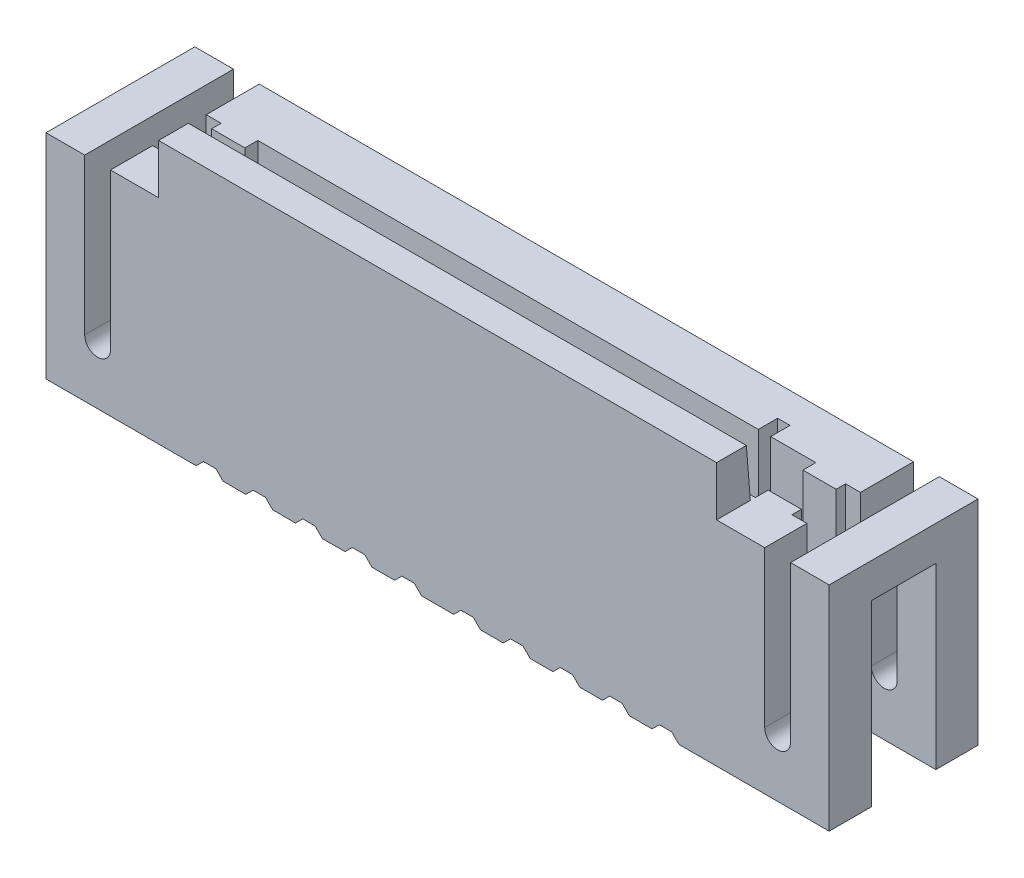
from build123d import *

# Parameters (mm, degrees)
BOSS_EXTRUDE1_DEPTH             = 3
CUT_EXTRUDE1_DEPTH              = 19.761966848
SKETCH3_W                       = 16.06
SKETCH3_H                       = 1.22
CUT_EXTRUDE2_DEPTH              = 3
CUT_EXTRUDE3_DEPTH              = 12.557681428
CUT_EXTRUDE3_DEPTH_BACK         = 12.557681428
SKETCH5_W                       = 1.3
SKETCH5_H                       = 3.6
CUT_EXTRUDE4_DEPTH              = 1.6
CUT_EXTRUDE5_DEPTH              = 1.6
SKETCH8_W                       = 0.3
SKETCH8_H                       = 1.3
BOSS_EXTRUDE3_DEPTH             = 0.3
CUT_EXTRUDE6_REACH              = 13.558
SKETCH9_W                       = 0.97
SKETCH9_H                       = 0.7
SKETCH10_W                      = 1.3
SKETCH10_H                      = 0.995055469
CUT_EXTRUDE7_DEPTH              = 0.3
SKETCH11_W                      = 1.3
SKETCH11_H                      = 1.339878891
CUT_EXTRUDE8_DEPTH              = 0.3
SKETCH12_W                      = 0.22
SKETCH12_H                      = 2.3
BOSS_EXTRUDE4_DEPTH             = 0.3
SZKIC1_W                        = 4.81
SZKIC1_H                        = 6.619114068
WYTNIJ_WYCI_GNI_CIE1_DEPTH      = 12.050452479
WYTNIJ_WYCI_GNI_CIE1_DEPTH_BACK = 12.050452479


with BuildPart() as part:
    # Sketch1 → Boss-Extrude1 (new body)
    with BuildSketch(Plane.XY):
        with BuildLine():
            Line((4.729085478, -2.65), (4.875, -2.504085478))
            Line((4.875, -2.504085478), (5.125, -2.504085478))
            Line((5.125, -2.504085478), (5.270914522, -2.65))
            Line((5.270914522, -2.65), (5.729085478, -2.65))
            Line((5.729085478, -2.65), (5.875, -2.504085478))
            Line((5.875, -2.504085478), (6.125, -2.504085478))
            Line((6.125, -2.504085478), (6.270914522, -2.65))
            Line((6.270914522, -2.65), (6.729085478, -2.65))
            Line((6.729085478, -2.65), (6.875, -2.504085478))
            Line((6.875, -2.504085478), (7.125, -2.504085478))
            Line((7.125, -2.504085478), (7.270914522, -2.65))
            Line((7.270914522, -2.65), (10.3, -2.65))
            Line((10.3, -2.65), (10.3, 1.65))
            Line((10.3, 1.65), (9.52, 1.65))
            Line((9.52, 1.65), (9.52, -1.49))
            ThreePointArc((9.52, -1.49), (9.26, -1.75), (9, -1.49))
            Line((9, -1.49), (9, 1.65))
            Line((9, 1.65), (8.03, 1.65))
            Line((8.03, 1.65), (8.03, 2.65))
            Line((8.03, 2.65), (-8.03, 2.65))
            Line((-8.03, 2.65), (-8.03, 1.65))
            Line((-8.03, 1.65), (-9, 1.65))
            Line((-9, 1.65), (-9, -1.49))
            ThreePointArc((-9, -1.49), (-9.26, -1.75), (-9.52, -1.49))
            Line((-9.52, -1.49), (-9.52, 1.65))
            Line((-9.52, 1.65), (-10.3, 1.65))
            Line((-10.3, 1.65), (-10.3, -2.65))
            Line((-10.3, -2.65), (-7.270914522, -2.65))
            Line((-7.270914522, -2.65), (-7.125, -2.504085478))
            Line((-7.125, -2.504085478), (-6.875, -2.504085478))
            Line((-6.875, -2.504085478), (-6.729085478, -2.65))
            Line((-6.729085478, -2.65), (-6.270914522, -2.65))
            Line((-6.270914522, -2.65), (-6.125, -2.504085478))
            Line((-6.125, -2.504085478), (-5.875, -2.504085478))
            Line((-5.875, -2.504085478), (-5.729085478, -2.65))
            Line((-5.729085478, -2.65), (-5.270914522, -2.65))
            Line((-5.270914522, -2.65), (-5.125, -2.504085478))
            Line((-5.125, -2.504085478), (-4.875, -2.504085478))
            Line((-4.875, -2.504085478), (-4.729085478, -2.65))
            Line((-4.729085478, -2.65), (-4.270914522, -2.65))
            Line((-4.270914522, -2.65), (-4.125, -2.504085478))
            Line((-4.125, -2.504085478), (-3.875, -2.504085478))
            Line((-3.875, -2.504085478), (-3.729085478, -2.65))
            Line((-3.729085478, -2.65), (-3.270914522, -2.65))
            Line((-3.270914522, -2.65), (-3.125, -2.504085478))
            Line((-3.125, -2.504085478), (-2.875, -2.504085478))
            Line((-2.875, -2.504085478), (-2.729085478, -2.65))
            Line((-2.729085478, -2.65), (-2.270914522, -2.65))
            Line((-2.270914522, -2.65), (-2.125, -2.504085478))
            Line((-2.125, -2.504085478), (-1.875, -2.504085478))
            Line((-1.875, -2.504085478), (-1.729085478, -2.65))
            Line((-1.729085478, -2.65), (-1.270914522, -2.65))
            Line((-1.270914522, -2.65), (-1.125, -2.504085478))
            Line((-1.125, -2.504085478), (-0.875, -2.504085478))
            Line((-0.875, -2.504085478), (-0.729085478, -2.65))
            Line((-0.729085478, -2.65), (-0.270914522, -2.65))
            Line((-0.270914522, -2.65), (-0.125, -2.504085478))
            Line((-0.125, -2.504085478), (0.125, -2.504085478))
            Line((0.125, -2.504085478), (0.270914522, -2.65))
            Line((0.270914522, -2.65), (0.729085478, -2.65))
            Line((0.729085478, -2.65), (0.875, -2.504085478))
            Line((0.875, -2.504085478), (1.125, -2.504085478))
            Line((1.125, -2.504085478), (1.270914522, -2.65))
            Line((1.270914522, -2.65), (1.729085478, -2.65))
            Line((1.729085478, -2.65), (1.875, -2.504085478))
            Line((1.875, -2.504085478), (2.125, -2.504085478))
            Line((2.125, -2.504085478), (2.270914522, -2.65))
            Line((2.270914522, -2.65), (2.729085478, -2.65))
            Line((2.729085478, -2.65), (2.875, -2.504085478))
            Line((2.875, -2.504085478), (3.125, -2.504085478))
            Line((3.125, -2.504085478), (3.270914522, -2.65))
            Line((3.270914522, -2.65), (3.729085478, -2.65))
            Line((3.729085478, -2.65), (3.875, -2.504085478))
            Line((3.875, -2.504085478), (4.125, -2.504085478))
            Line((4.125, -2.504085478), (4.270914522, -2.65))
            Line((4.270914522, -2.65), (4.729085478, -2.65))
        make_face()
    extrude(amount=BOSS_EXTRUDE1_DEPTH)

    # Sketch2 → Cut-Extrude1 (cut, through all)
    with BuildSketch(Plane(origin=(8.03, 0, 0), x_dir=(0, 0, -1), z_dir=(1, 0, 0))):
        Polygon((-2.4, 2.65), (-2.32, 1.65), (0.208388731, 1.65), (0.247686287, 2.908353898), align=None)
    extrude(amount=-CUT_EXTRUDE1_DEPTH, mode=Mode.SUBTRACT)

    # Sketch3 → Cut-Extrude2 (cut)
    with BuildSketch(Plane(origin=(0, 1.65, 0), x_dir=(1, 0, 0), z_dir=(0, 1, 0))):
        with Locations((0, -1.61)):
            Rectangle(SKETCH3_W, SKETCH3_H)
    extrude(amount=-CUT_EXTRUDE2_DEPTH, mode=Mode.SUBTRACT)

    # Sketch4 → Cut-Extrude3 (cut, two sides)
    with BuildSketch(Plane(origin=(0, 1.65, 0), x_dir=(1, 0, 0), z_dir=(0, 1, 0))) as cut_extrude3_sk:
        Polygon((7.12, -1), (7.12, -0.61), (6.87, -0.61), (6.87, -1.06), (7.12, -1.06), align=None)
    extrude(amount=CUT_EXTRUDE3_DEPTH, mode=Mode.SUBTRACT)
    extrude(cut_extrude3_sk.sketch, amount=-CUT_EXTRUDE3_DEPTH_BACK, mode=Mode.SUBTRACT)

    # Sketch5 → Cut-Extrude4 (cut)
    with BuildSketch(Plane.ZY.offset(10.3)):
        with Locations((1.5, -0.85)):
            Rectangle(SKETCH5_W, SKETCH5_H)
    extrude(amount=-CUT_EXTRUDE4_DEPTH, mode=Mode.SUBTRACT)

    # Sketch6 → Cut-Extrude5 (cut)
    with BuildSketch(Plane(origin=(10.3, 0, 0), x_dir=(0, 0, -1), z_dir=(1, 0, 0))):
        Polygon((-2.15, 0.95), (-0.85, 0.95), (-0.85, -1.49), (-0.85, -2.65), (-2.15, -2.65), (-2.15, -1.49), align=None)
    extrude(amount=-CUT_EXTRUDE5_DEPTH, mode=Mode.SUBTRACT)

    # Sketch8 → Boss-Extrude3 (add)
    with BuildSketch(Plane.ZY.offset(8.7)):
        with Locations((2, -2)):
            Rectangle(SKETCH8_W, SKETCH8_H)
    boss_extrude3 = extrude(amount=BOSS_EXTRUDE3_DEPTH)

    # Cut-Extrude6: up to this face of the body (flat: up to its plane)
    cut_extrude6_end = Plane(part.part.faces().sort_by_distance((-0.005359277, -1.35, 1.610444372))[0])
    # Sketch9 → Cut-Extrude6 (cut, up to the picked face)
    with BuildSketch(Plane(origin=(0, 1.65, 0), x_dir=(1, 0, 0), z_dir=(0, 1, 0)), mode=Mode.PRIVATE) as cut_extrude6_sk1:
        with Locations((-8.515, -1.61)):
            Rectangle(SKETCH9_W, SKETCH9_H)
    cut_extrude6_tool1 = split(extrude(cut_extrude6_sk1.sketch, amount=-CUT_EXTRUDE6_REACH, mode=Mode.PRIVATE), bisect_by=cut_extrude6_end, keep=Keep.BOTH, mode=Mode.PRIVATE)
    cut_extrude6 = cut_extrude6_tool1.solids().sort_by(Axis((-8.515, 1.65, 1.61), (0, -1, 0)))[0]
    add(cut_extrude6, mode=Mode.SUBTRACT)

    # Mirror2: Cut-Extrude6 across plane
    add(cut_extrude6.mirror(Plane.ZY), mode=Mode.SUBTRACT)

    # Sketch10 → Cut-Extrude7 (cut)
    with BuildSketch(Plane.ZY.offset(9)):
        with Locations((1.5, 1.447527735)):
            Rectangle(SKETCH10_W, SKETCH10_H)
    extrude(amount=-CUT_EXTRUDE7_DEPTH, mode=Mode.SUBTRACT)

    # Sketch11 → Cut-Extrude8 (cut)
    with BuildSketch(Plane(origin=(9, 0, 0), x_dir=(0, 0, -1), z_dir=(1, 0, 0))):
        with Locations((-1.5, 1.619939446)):
            Rectangle(SKETCH11_W, SKETCH11_H)
    extrude(amount=-CUT_EXTRUDE8_DEPTH, mode=Mode.SUBTRACT)

    # Sketch12 → Boss-Extrude4 (add)
    with BuildSketch(Plane.ZY.offset(8.7)):
        with Locations((0.96, 0.5)):
            Rectangle(SKETCH12_W, SKETCH12_H)
    boss_extrude4 = extrude(amount=BOSS_EXTRUDE4_DEPTH)

    # Mirror4: Boss-Extrude4 across plane
    add(boss_extrude4.mirror(Plane.ZY))

    # Mirror5: Boss-Extrude3 across plane
    add(boss_extrude3.mirror(Plane.ZY))

    # Szkic1 → Wytnij-wyci_gni_cie1 (cut, two sides)
    with BuildSketch(Plane.XY.offset(3)) as wytnij_wyci_gni_cie1_sk:
        with Locations((0, -0.145396272)):
            Rectangle(SZKIC1_W, SZKIC1_H)
    extrude(amount=WYTNIJ_WYCI_GNI_CIE1_DEPTH, mode=Mode.SUBTRACT)
    extrude(wytnij_wyci_gni_cie1_sk.sketch, amount=-WYTNIJ_WYCI_GNI_CIE1_DEPTH_BACK, mode=Mode.SUBTRACT)


with BuildPart() as wytnij_wyci_gni_cie1_piece_1:
    # of the separate pieces the step leaves, piece 1, a body of its own (wytnij_wyci_gni_cie1_pieces)
    add(part.part.solids().sort_by_distance((-2.405, -2.65, 0))[0])


with BuildPart() as wytnij_wyci_gni_cie1_piece_2:
    # of the separate pieces the step leaves, piece 2, a body of its own (wytnij_wyci_gni_cie1_pieces)
    add(part.part.solids().sort_by_distance((3.729085478, -2.65, 0))[0])


with BuildPart() as wytnij_wyci_gni_cie1_piece_1_1:
    # Obiekt-Przenie_Kopiuj1: moved
    add(wytnij_wyci_gni_cie1_piece_1.part.moved(Location((4.81, 0, 0))))

    # Po_cz1: union Wytnij-wyci_gni_cie1 piece 2
    add(wytnij_wyci_gni_cie1_piece_2.part)


solid = wytnij_wyci_gni_cie1_piece_1_1.part
